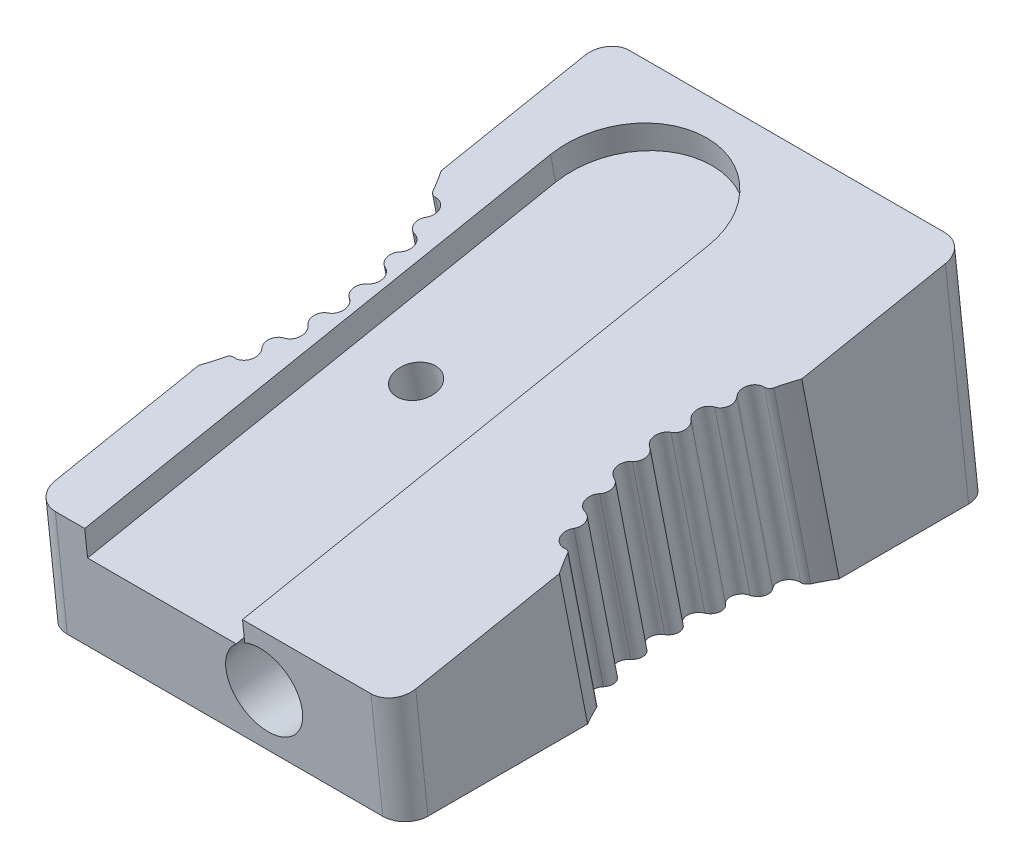
from build123d import *

# Parameters (mm, degrees)
BOSS_EXTRUDE1_DEPTH          = 8
CUT_EXTRUDE2_DEPTH           = 1.2
CUT_EXTRUDE3_DEPTH           = 10.965900881
FILLET1_R                    = 1
M2_2X0_45_TAPPED_HOLE1_D     = 1.75
M2_2X0_45_TAPPED_HOLE1_DEPTH = 3.474246958
M2_2X0_45_TAPPED_HOLE1_TIP   = 0.525753042
CUT_EXTRUDE4_DEPTH           = 10.965900881


with BuildPart() as part:
    # Sketch1 → Boss-Extrude1 (new body, symmetric)
    with BuildSketch(Plane(origin=(0, 0, 0), x_dir=(0, 0, -1), z_dir=(1, 0, 0))):
        Polygon((13, 0), (-13, 0), (-13.522642316, 4.972609477), (11.954212859, 9.95), align=None)
    extrude(amount=BOSS_EXTRUDE1_DEPTH, both=True)

    # Sketch2 → Cut-Extrude2 (cut)
    with BuildSketch(Plane(origin=(0, 7.334562502, 1.432946949), x_dir=(1, 0, 0), z_dir=(0, 0.981444969, 0.19174403))):
        with BuildLine():
            Line((-5.7, -12.995337767), (-5.7, 8.740255167))
            ThreePointArc((-5.7, 8.740255167), (-2.2, 12.240255167), (1.3, 8.740255167))
            Line((1.3, 8.740255167), (1.3, -12.995337767))
            Line((1.3, -12.995337767), (-5.7, -12.995337767))
        make_face()
    extrude(amount=-CUT_EXTRUDE2_DEPTH, mode=Mode.SUBTRACT)

    # Sketch5 → Cut-Extrude3 (cut, through all)
    with BuildSketch(Plane(origin=(0, 7.334562502, 1.432946949), x_dir=(1, 0, 0), z_dir=(0, 0.981444969, 0.19174403))):
        with BuildLine():
            Line((-8, 6.140255167), (-8, -4.818261086))
            ThreePointArc((-8, -4.818261086), (-6.5, 0.660997041), (-8, 6.140255167))
        make_face()
        with BuildLine():
            Line((8, 6.140255167), (8, -4.818261086))
            ThreePointArc((8, -4.818261086), (6.5, 0.660997041), (8, 6.140255167))
        make_face()
    extrude(amount=-CUT_EXTRUDE3_DEPTH, mode=Mode.SUBTRACT)

    # Fillet1
    fillet1_edges = [part.edges().sort_by_distance(p)[0] for p in [
        (8, 2.486304738, 13.261321158),
        (8, 4.975, -12.47710643),
        (-8, 2.486304738, 13.261321158),
        (-8, 4.975, -12.47710643),
    ]]
    fillet(fillet1_edges, radius=FILLET1_R)

    # Sketch6 → Cut-Revolve1 (revolve, cut)
    with BuildSketch(Plane(origin=(2, 0, 0), x_dir=(0, 0, -1), z_dir=(1, 0, 0))):
        Polygon((13.04508728, 9.137795416), (-14.42511425, 3.992284126), (-14.282095982, 2.631556203), (-14.256713544, 2.390058443), (13.472498816, 5.071246296), align=None)
    revolve(axis=Axis((2, 2.390058443, 14.256713544), (0, 0.096242959, -0.995357872)), mode=Mode.SUBTRACT)

    # M2.2x0.45 Tapped Hole1
    with Locations(Plane(origin=(0, 6.156828539, 1.202854113), x_dir=(1, 0, 0), z_dir=(0, 0.981444969, 0.19174403))):
        with Locations((-2.9, -0.424399477)):
            Hole(M2_2X0_45_TAPPED_HOLE1_D / 2, depth=M2_2X0_45_TAPPED_HOLE1_DEPTH)
            with Locations((0, 0, -(M2_2X0_45_TAPPED_HOLE1_DEPTH + M2_2X0_45_TAPPED_HOLE1_TIP / 2))):  # 118° drill point
                Cone(0, M2_2X0_45_TAPPED_HOLE1_D / 2, M2_2X0_45_TAPPED_HOLE1_TIP, mode=Mode.SUBTRACT)

    # Sketch9 → Cut-Extrude4 (cut, through all)
    with BuildSketch(Plane(origin=(0, 7.334562502, 1.432946949), x_dir=(1, 0, 0), z_dir=(0, 0.981444969, 0.19174403))):
        with BuildLine():
            ThreePointArc((-7.289795354, 5.159702376), (-7.451242382, 5.201326159), (-7.563470071, 5.324625097))
            ThreePointArc((-7.563470071, 5.324625097), (-7.252547552, 4.613795693), (-6.993667337, 3.882405038))
            ThreePointArc((-6.993667337, 3.882405038), (-7.004481287, 4.117448052), (-6.897853081, 4.327192148))
            ThreePointArc((-6.897853081, 4.327192148), (-6.818575776, 4.873033057), (-7.289795354, 5.159702376))
        make_face()
        with BuildLine():
            ThreePointArc((-6.660871352, 3.572142615), (-6.868230387, 3.683337889), (-6.993667337, 3.882405038))
            ThreePointArc((-6.993667337, 3.882405038), (-6.776841479, 3.085777587), (-6.621748536, 2.274867649))
            ThreePointArc((-6.621748536, 2.274867649), (-6.596489986, 2.508799625), (-6.459039737, 2.69976976))
            ThreePointArc((-6.459039737, 2.69976976), (-6.289708944, 3.198480265), (-6.660871352, 3.572142615))
        make_face()
        with BuildLine():
            ThreePointArc((-6.340315921, 1.917360153), (-6.528230594, 2.05895899), (-6.621748536, 2.274867649))
            ThreePointArc((-6.621748536, 2.274867649), (-6.529302038, 1.454451661), (-6.500046516, 0.629362053))
            ThreePointArc((-6.500046516, 0.629362053), (-6.439309701, 0.856679466), (-6.274271086, 1.024382842))
            ThreePointArc((-6.274271086, 1.024382842), (-6.030663985, 1.491331089), (-6.340315921, 1.917360153))
        make_face()
        with BuildLine():
            ThreePointArc((-6.2765983, 0.23302027), (-6.440647698, 0.401691388), (-6.500046516, 0.629362053))
            ThreePointArc((-6.500046516, 0.629362053), (-6.534154287, -0.195541178), (-6.631424447, -1.015399212))
            ThreePointArc((-6.631424447, -1.015399212), (-6.536638256, -0.80004432), (-6.347894026, -0.659553155))
            ThreePointArc((-6.347894026, -0.659553155), (-6.035741762, -0.235352673), (-6.2765983, 0.23302027))
        make_face()
        with BuildLine():
            ThreePointArc((-6.47121752, -1.441250956), (-6.607542206, -1.249475706), (-6.631424447, -1.015399212))
            ThreePointArc((-6.631424447, -1.015399212), (-6.791284069, -1.825382978), (-7.012791541, -2.620721422))
            ThreePointArc((-7.012791541, -2.620721422), (-6.886185953, -2.422395441), (-6.678176493, -2.312421653))
            ThreePointArc((-6.678176493, -2.312421653), (-6.304822815, -1.940948752), (-6.47121752, -1.441250956))
        make_face()
        with BuildLine():
            ThreePointArc((-6.919594936, -3.066064322), (-7.024987686, -2.855696746), (-7.012791541, -2.620721422))
            ThreePointArc((-7.012791541, -2.620721422), (-7.264215038, -3.321206437), (-7.563470071, -4.002631015))
            ThreePointArc((-7.563470071, -4.002631015), (-7.47948201, -3.914560625), (-7.359806711, -3.892465134))
            ThreePointArc((-7.359806711, -3.892465134), (-6.85334699, -3.631801278), (-6.919594936, -3.066064322))
        make_face()
        with BuildLine():
            ThreePointArc((7.563470071, -4.002631015), (7.264215036, -3.321206432), (7.012791537, -2.620721412))
            ThreePointArc((7.012791537, -2.620721412), (7.024987687, -2.855696741), (6.919594936, -3.066064322))
            ThreePointArc((6.919594936, -3.066064322), (6.85334699, -3.631801278), (7.359806711, -3.892465134))
            ThreePointArc((7.359806711, -3.892465134), (7.47948201, -3.914560625), (7.563470071, -4.002631015))
        make_face()
        with BuildLine():
            ThreePointArc((7.012791537, -2.620721412), (6.791284072, -1.825382992), (6.631424452, -1.01539925))
            ThreePointArc((6.631424452, -1.01539925), (6.607542199, -1.249475724), (6.47121752, -1.441250956))
            ThreePointArc((6.47121752, -1.441250956), (6.304822815, -1.940948752), (6.678176493, -2.312421653))
            ThreePointArc((6.678176493, -2.312421653), (6.886185949, -2.422395438), (7.012791537, -2.620721412))
        make_face()
        with BuildLine():
            ThreePointArc((6.631424452, -1.01539925), (6.534154286, -0.195541171), (6.500046515, 0.629362105))
            ThreePointArc((6.500046515, 0.629362105), (6.440647711, 0.401691411), (6.2765983, 0.23302027))
            ThreePointArc((6.2765983, 0.23302027), (6.035741762, -0.235352673), (6.347894026, -0.659553155))
            ThreePointArc((6.347894026, -0.659553155), (6.536638268, -0.800044334), (6.631424452, -1.01539925))
        make_face()
        with BuildLine():
            ThreePointArc((6.500046515, 0.629362105), (6.52930204, 1.454451696), (6.621748538, 2.274867666))
            ThreePointArc((6.621748538, 2.274867666), (6.528230599, 2.058958996), (6.340315921, 1.917360153))
            ThreePointArc((6.340315921, 1.917360153), (6.030663985, 1.491331089), (6.274271086, 1.024382842))
            ThreePointArc((6.274271086, 1.024382842), (6.439309688, 0.856679489), (6.500046515, 0.629362105))
        make_face()
        with BuildLine():
            ThreePointArc((6.621748538, 2.274867666), (6.776841483, 3.085777604), (6.993667342, 3.882405056))
            ThreePointArc((6.993667342, 3.882405056), (6.868230394, 3.683337895), (6.660871352, 3.572142615))
            ThreePointArc((6.660871352, 3.572142615), (6.289708944, 3.198480265), (6.459039737, 2.69976976))
            ThreePointArc((6.459039737, 2.69976976), (6.596489983, 2.508799632), (6.621748538, 2.274867666))
        make_face()
        with BuildLine():
            ThreePointArc((7.563470071, 5.324625097), (7.451242382, 5.201326159), (7.289795354, 5.159702376))
            ThreePointArc((7.289795354, 5.159702376), (6.818575776, 4.873033057), (6.897853081, 4.327192148))
            ThreePointArc((6.897853081, 4.327192148), (7.004481285, 4.117448061), (6.993667342, 3.882405056))
            ThreePointArc((6.993667342, 3.882405056), (7.252547555, 4.613795701), (7.563470071, 5.324625097))
        make_face()
    extrude(amount=-CUT_EXTRUDE4_DEPTH, mode=Mode.SUBTRACT)


solid = part.part
